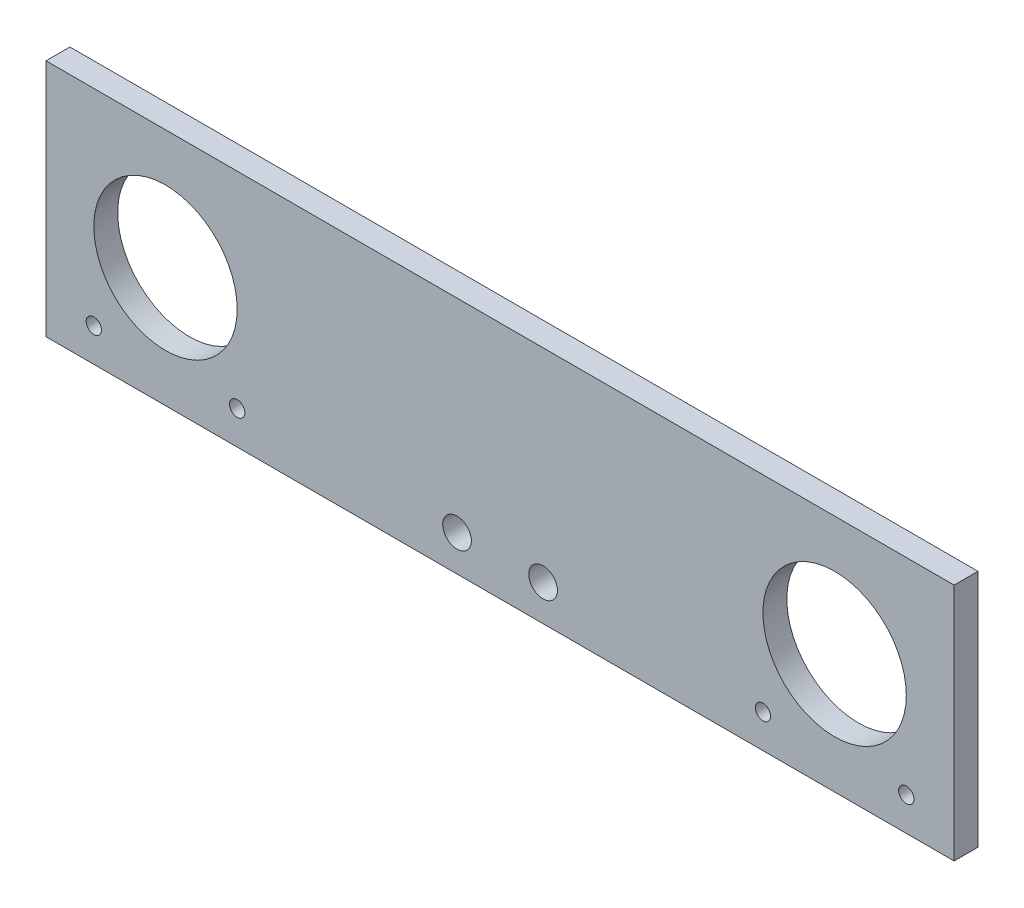
from build123d import *

# Parameters (mm, degrees)
SKETCH1_W           = 190
SKETCH1_H           = 50
SKETCH1_R           = 15
SKETCH1_R_2         = 1.6
SKETCH1_R_3         = 3
BOSS_EXTRUDE1_DEPTH = 5


with BuildPart() as part:
    # Sketch1 → Boss-Extrude1 (new body)
    with BuildSketch(Plane.XY):
        with Locations((95, 25)):
            Rectangle(SKETCH1_W, SKETCH1_H)
        with Locations((25, 25)):
            Circle(SKETCH1_R, mode=Mode.SUBTRACT)
        with Locations((165, 25)):
            Circle(SKETCH1_R, mode=Mode.SUBTRACT)
        with Locations((40, 7)):
            Circle(SKETCH1_R_2, mode=Mode.SUBTRACT)
        with Locations((180, 7)):
            Circle(SKETCH1_R_2, mode=Mode.SUBTRACT)
        with Locations((150, 7)):
            Circle(SKETCH1_R_2, mode=Mode.SUBTRACT)
        with Locations((10, 7)):
            Circle(SKETCH1_R_2, mode=Mode.SUBTRACT)
        with Locations((86, 7.5)):
            Circle(SKETCH1_R_3, mode=Mode.SUBTRACT)
        with Locations((104, 7.5)):
            Circle(SKETCH1_R_3, mode=Mode.SUBTRACT)
    extrude(amount=BOSS_EXTRUDE1_DEPTH)


solid = part.part
